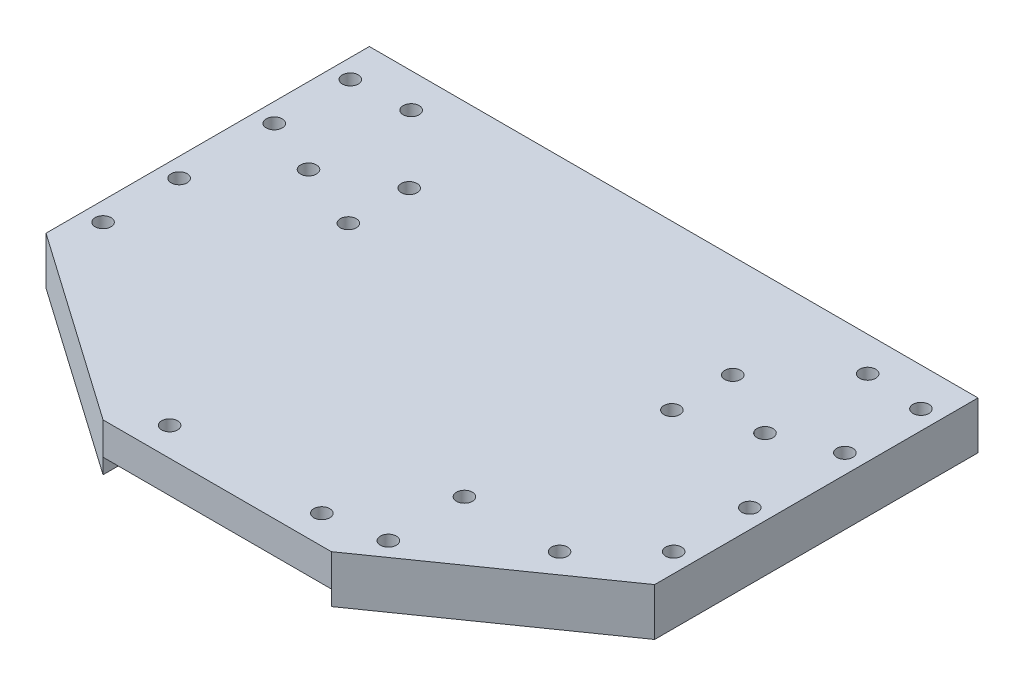
from build123d import *

# Parameters (mm, degrees)
BOSS_EXTRUDE2_DEPTH = 12.5
SKETCH2_R           = 2.1
BOSS_EXTRUDE3_DEPTH = 29
SKETCH4_W           = 9
SKETCH4_H           = 3.5
CUT_EXTRUDE1_DEPTH  = 73
CHAMFER1_SIZE       = 3
SKETCH5_W           = 60
SKETCH5_H           = 15
SKETCH5_R           = 2.89755201
CUT_EXTRUDE2_DEPTH  = 4
SKETCH6_R           = 2.89755201
CUT_EXTRUDE3_DEPTH  = 26
SKETCH7_R           = 2.1
CUT_EXTRUDE4_DEPTH  = 26
SKETCH8_R           = 2.1
CUT_EXTRUDE5_DEPTH  = 26
SKETCH9_W           = 20
SKETCH9_H           = 45
CUT_EXTRUDE8_DEPTH  = 5
SKETCH10_W          = 1.5
SKETCH10_H          = 3.5
BOSS_EXTRUDE4_DEPTH = 9.75
SKETCH11_R          = 2.1
CUT_EXTRUDE9_DEPTH  = 22
SKETCH12_R          = 2.1
BOSS_EXTRUDE5_DEPTH = 12.5
SKETCH13_W          = 36.022900052
SKETCH13_H          = 69.947378741
CUT_EXTRUDE10_DEPTH = 29
SKETCH14_R          = 2.89755201
SKETCH14_R_2        = 2.1
BOSS_EXTRUDE6_DEPTH = 8.5
SKETCH15_R          = 2.1
CUT_EXTRUDE11_DEPTH = 38
SKETCH16_R          = 2.1
CUT_EXTRUDE12_DEPTH = 38


with BuildPart() as part:
    # Sketch1 → Boss-Extrude2 (new body)
    with BuildSketch(Plane(origin=(0, 0, 0), x_dir=(1, 0, 0), z_dir=(0, 1, 0))):
        Polygon((-80, -42.5), (-80, 42.5), (80, 42.5), (80, -42.5), (30, -77.5), (-30, -77.5), align=None)
    extrude(amount=BOSS_EXTRUDE2_DEPTH)

    # Sketch2 → Boss-Extrude3 (add)
    with BuildSketch(Plane(origin=(0, 12.5, 0), x_dir=(1, 0, 0), z_dir=(0, 1, 0))):
        with BuildLine():
            Line((10.25, -47.5), (-10.25, -47.5))
            Line((-10.25, -47.5), (-10.25, -7))
            Line((-10.25, -7), (-3, -7))
            Line((-3, -7), (-3, -3.640312424))
            ThreePointArc((-3, -3.640312424), (-7.1, -3), (-3, -2.359687576))
            Line((-3, -2.359687576), (-3, 2.75))
            Line((-3, 2.75), (-15, 2.75))
            Line((-15, 2.75), (-15, -57.25))
            Line((-15, -57.25), (15, -57.25))
            Line((15, -57.25), (15, 2.75))
            Line((15, 2.75), (3, 2.75))
            Line((3, 2.75), (3, -2.359687576))
            ThreePointArc((3, -2.359687576), (5.324037035, -0.925150608), (7.1, -3))
            ThreePointArc((7.1, -3), (5.324037035, -5.074849392), (3, -3.640312424))
            Line((3, -3.640312424), (3, -7))
            Line((3, -7), (10.25, -7))
            Line((10.25, -7), (10.25, -47.5))
        make_face()
        with Locations((-5, -51.5)):
            Circle(SKETCH2_R, mode=Mode.SUBTRACT)
        with Locations((5, -51.5)):
            Circle(SKETCH2_R, mode=Mode.SUBTRACT)
    extrude(amount=BOSS_EXTRUDE3_DEPTH)

    # Sketch4 → Cut-Extrude1 (cut)
    with BuildSketch(Plane.XY.offset(57.25)):
        with Locations((5, 35.75)):
            Rectangle(SKETCH4_W, SKETCH4_H)
        with Locations((-5, 35.75)):
            Rectangle(SKETCH4_W, SKETCH4_H)
    extrude(amount=-CUT_EXTRUDE1_DEPTH, mode=Mode.SUBTRACT)

    # Chamfer1
    chamfer1_edges = [part.edges().sort_by_distance(p)[0] for p in [
        (-15, 27, -2.75),
        (-15, 27, 57.25),
        (15, 27, 57.25),
        (15, 27, -2.75),
    ]]
    chamfer(chamfer1_edges, length=CHAMFER1_SIZE)

    # Sketch5 → Cut-Extrude2 (cut)
    with BuildSketch(Plane.XZ):
        with Locations((0, 70)):
            Rectangle(SKETCH5_W, SKETCH5_H)
        with Locations((-20, 70)):
            Circle(SKETCH5_R, mode=Mode.SUBTRACT)
        with Locations((20, 70)):
            Circle(SKETCH5_R, mode=Mode.SUBTRACT)
    extrude(amount=-CUT_EXTRUDE2_DEPTH, mode=Mode.SUBTRACT)

    # Sketch6 → Cut-Extrude3 (cut)
    with BuildSketch(Plane(origin=(0, 0, 0), x_dir=(-1, 0, 0), z_dir=(0, -1, 0))):
        with Locations((20, -70)):
            Circle(SKETCH6_R)
        with Locations((-20, -70)):
            Circle(SKETCH6_R)
    extrude(amount=-CUT_EXTRUDE3_DEPTH, mode=Mode.SUBTRACT)

    # Sketch7 → Cut-Extrude4 (cut)
    with BuildSketch(Plane(origin=(0, 12.5, 0), x_dir=(1, 0, 0), z_dir=(0, 1, 0))):
        with Locations((-75, 32.5)):
            Circle(SKETCH7_R)
        with Locations((-75, 12.5)):
            Circle(SKETCH7_R)
        with Locations((-75, -12.5)):
            Circle(SKETCH7_R)
        with Locations((-75, -32.5)):
            Circle(SKETCH7_R)
        with Locations((75, -32.5)):
            Circle(SKETCH7_R)
        with Locations((75, -12.5)):
            Circle(SKETCH7_R)
        with Locations((75, 12.5)):
            Circle(SKETCH7_R)
        with Locations((75, 32.5)):
            Circle(SKETCH7_R)
    extrude(amount=-CUT_EXTRUDE4_DEPTH, mode=Mode.SUBTRACT)

    # Sketch8 → Cut-Extrude5 (cut)
    with BuildSketch(Plane.XZ):
        with Locations((-60, -6.5)):
            Circle(SKETCH8_R)
        with Locations((-60, -33.5)):
            Circle(SKETCH8_R)
        with Locations((60, -6.5)):
            Circle(SKETCH8_R)
        with Locations((60, -33.5)):
            Circle(SKETCH8_R)
    extrude(amount=-CUT_EXTRUDE5_DEPTH, mode=Mode.SUBTRACT)

    # Sketch9 → Cut-Extrude8 (cut)
    with BuildSketch(Plane.XZ):
        with Locations((-60, -20)):
            Rectangle(SKETCH9_W, SKETCH9_H)
        with Locations((60, -20)):
            Rectangle(SKETCH9_W, SKETCH9_H)
    extrude(amount=-CUT_EXTRUDE8_DEPTH, mode=Mode.SUBTRACT)

    # Sketch10 → Boss-Extrude4 (add)
    with BuildSketch(Plane.XY.offset(57.25)):
        with Locations((0, 35.75)):
            Rectangle(SKETCH10_W, SKETCH10_H)
    extrude(amount=-BOSS_EXTRUDE4_DEPTH)

    # Sketch11 → Cut-Extrude9 (cut)
    with BuildSketch(Plane(origin=(0, 12.5, 0), x_dir=(1, 0, 0), z_dir=(0, 1, 0))):
        with Locations((-42.5, 37.25)):
            Circle(SKETCH11_R)
        with Locations((-42.5, 23.25)):
            Circle(SKETCH11_R)
    extrude(amount=-CUT_EXTRUDE9_DEPTH, mode=Mode.SUBTRACT)

    # Sketch12 → Boss-Extrude5 (add, through all)
    with BuildSketch(Plane(origin=(0, 12.5, 0), x_dir=(1, 0, 0), z_dir=(0, 1, 0))):
        with Locations((-42.5, 37.25)):
            Circle(SKETCH12_R)
        with Locations((-42.5, 23.25)):
            Circle(SKETCH12_R)
    extrude(amount=-BOSS_EXTRUDE5_DEPTH)

    # Sketch13 → Cut-Extrude10 (cut)
    with BuildSketch(Plane(origin=(0, 41.5, 0), x_dir=(1, 0, 0), z_dir=(0, 1, 0))):
        with Locations((0, -27.030330354)):
            Rectangle(SKETCH13_W, SKETCH13_H)
    extrude(amount=-CUT_EXTRUDE10_DEPTH, mode=Mode.SUBTRACT)

    # Sketch14 → Boss-Extrude6 (add)
    with BuildSketch(Plane(origin=(0, 12.5, 0), x_dir=(1, 0, 0), z_dir=(0, 1, 0))):
        with Locations((-20, -70)):
            Circle(SKETCH14_R)
        with Locations((-20, -70)):
            Circle(SKETCH14_R_2, mode=Mode.SUBTRACT)
        with Locations((20, -70)):
            Circle(SKETCH14_R)
        with Locations((20, -70)):
            Circle(SKETCH14_R_2, mode=Mode.SUBTRACT)
    extrude(amount=-BOSS_EXTRUDE6_DEPTH)

    # Sketch15 → Cut-Extrude11 (cut)
    with BuildSketch(Plane(origin=(0, 12.5, 0), x_dir=(1, 0, 0), z_dir=(0, 1, 0))):
        with Locations((-42.53, 15.5)):
            Circle(SKETCH15_R)
        with Locations((-42.53, -0.5)):
            Circle(SKETCH15_R)
        with Locations((42.53, 15.5)):
            Circle(SKETCH15_R)
        with Locations((42.53, -0.5)):
            Circle(SKETCH15_R)
    extrude(amount=-CUT_EXTRUDE11_DEPTH, mode=Mode.SUBTRACT)

    # Sketch16 → Cut-Extrude12 (cut)
    with BuildSketch(Plane(origin=(0, 12.5, 0), x_dir=(1, 0, 0), z_dir=(0, 1, 0))):
        with Locations((35, -47.5)):
            Circle(SKETCH16_R)
        with Locations((35, -67.5)):
            Circle(SKETCH16_R)
        with Locations((60, -47.5)):
            Circle(SKETCH16_R)
    extrude(amount=-CUT_EXTRUDE12_DEPTH, mode=Mode.SUBTRACT)


solid = part.part
